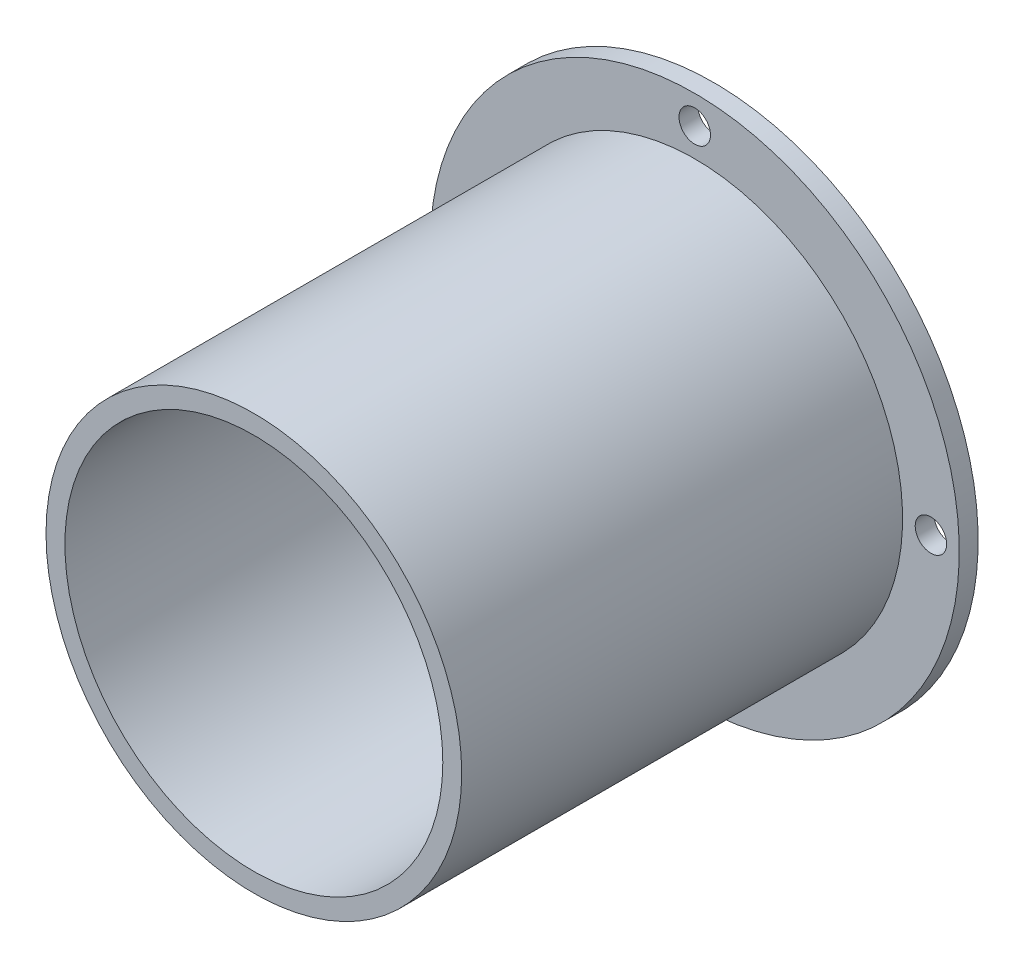
from build123d import *

# Parameters (mm, degrees)
SKETCH2_R           = 16.5
BOSS_EXTRUDE1_DEPTH = 33
SHELL2_T            = -1.5
SKETCH6_R           = 2.5
CUT_EXTRUDE3_DEPTH  = 1.5
SKETCH7_R           = 16.5
SKETCH7_R_2         = 15
BOSS_EXTRUDE3_DEPTH = 2
SKETCH8_R           = 21
SKETCH8_R_2         = 16.5
SKETCH8_R_3         = 1.25
BOSS_EXTRUDE4_DEPTH = 1.5


with BuildPart() as part:
    # Sketch2 → Boss-Extrude1 (new body)
    with BuildSketch(Plane.XY):
        Circle(SKETCH2_R)
    extrude(amount=BOSS_EXTRUDE1_DEPTH)

    # Shell2
    shell2_openings = [part.faces().sort_by_distance(p)[0] for p in [
        (0, 0, 33),
    ]]
    offset(amount=SHELL2_T, openings=shell2_openings, kind=Kind.INTERSECTION)

    # Sketch6 → Cut-Extrude3 (cut)
    with BuildSketch(Plane(origin=(0, 0, 0), x_dir=(-1, 0, 0), z_dir=(0, 0, -1))):
        Circle(SKETCH6_R)
    extrude(amount=-CUT_EXTRUDE3_DEPTH, mode=Mode.SUBTRACT)

    # Sketch7 → Boss-Extrude3 (add)
    with BuildSketch(Plane(origin=(0, 0, 0), x_dir=(-1, 0, 0), z_dir=(0, 0, -1))):
        Circle(SKETCH7_R)
        with Locations(Location((0, 0, 0), (0, 0, 180))):
            Circle(SKETCH7_R_2, mode=Mode.SUBTRACT)
    extrude(amount=BOSS_EXTRUDE3_DEPTH)


with BuildPart() as body_2:
    # Sketch8 → Boss-Extrude4 (new body)
    with BuildSketch(Plane(origin=(0, 0, -2), x_dir=(-1, 0, 0), z_dir=(0, 0, -1))):
        Circle(SKETCH8_R)
        Circle(SKETCH8_R_2, mode=Mode.SUBTRACT)
        with Locations((0, 18.75)):
            Circle(SKETCH8_R_3, mode=Mode.SUBTRACT)
        with Locations((18.75, 0)):
            Circle(SKETCH8_R_3, mode=Mode.SUBTRACT)
        with Locations((0, -18.75)):
            Circle(SKETCH8_R_3, mode=Mode.SUBTRACT)
        with Locations((-18.75, 0)):
            Circle(SKETCH8_R_3, mode=Mode.SUBTRACT)
    extrude(amount=BOSS_EXTRUDE4_DEPTH)


solid = Compound([part.part, body_2.part])
